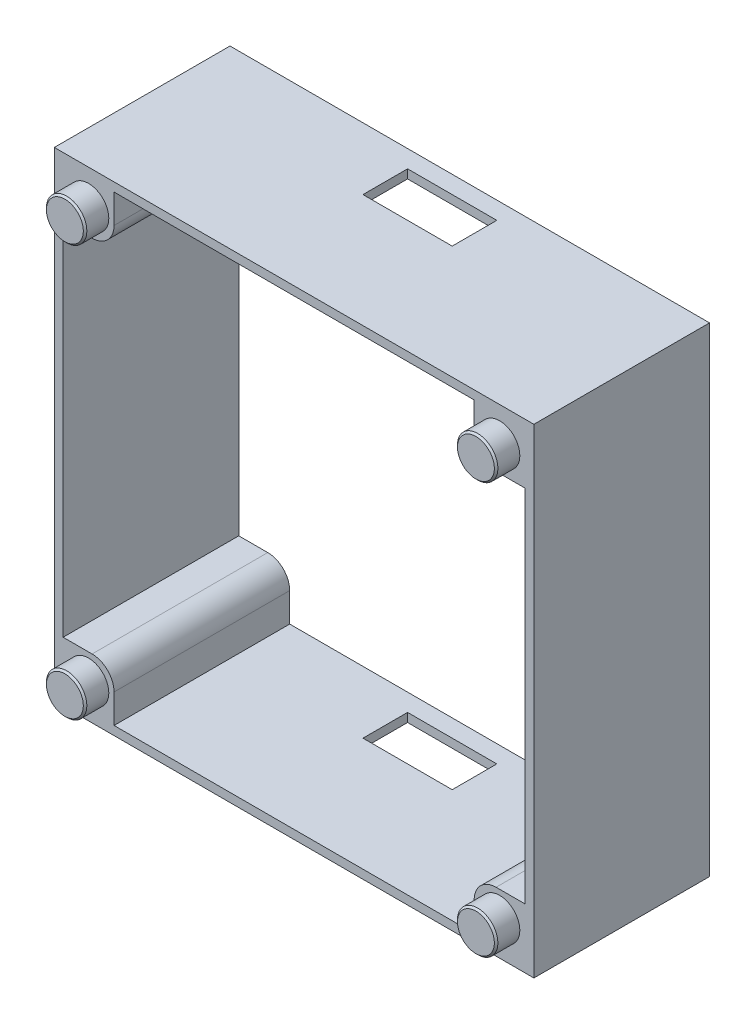
from build123d import *

# Parameters (mm, degrees)
SKICA1_W                 = 5.8
SKICA1_H                 = 5.8
SKICA1_W_2               = 1
SKICA1_H_2               = 41
SKICA1_W_3               = 41
SKICA1_H_3               = 1
P_IDAT_VYSUNUT_M2_DEPTH  = 20
ZAOBLIT1_R               = 2.5
SKICA2_R                 = 2.4
ODEBRAT_VYSUNUT_M1_DEPTH = 1.7
SKICA3_R                 = 2.3
P_IDAT_VYSUNUT_M3_DEPTH  = 2.7
ZKOSEN_1_SIZE            = 0.2
SKICA4_W                 = 10.16
SKICA4_H                 = 5.08
ODEBRAT_VYSUNUT_M2_DEPTH = 68.7


with BuildPart() as part:
    # Skica1 → Přidat vysunutím2 (new body)
    with BuildSketch(Plane.XY):
        Polygon((-27.3, 27.3), (-27.3, 20.5), (-26.3, 20.5), (-26.3, 26.3), (-20.5, 26.3), (-20.5, 27.3), align=None)
        with Locations((-23.4, 23.4)):
            Rectangle(SKICA1_W, SKICA1_H)
        Polygon((26.3, 20.5), (27.3, 20.5), (27.3, 27.3), (20.5, 27.3), (20.5, 26.3), (26.3, 26.3), align=None)
        with Locations((23.4, 23.4)):
            Rectangle(SKICA1_W, SKICA1_H)
        Polygon((20.5, -26.3), (20.5, -27.3), (27.3, -27.3), (27.3, -20.5), (26.3, -20.5), (26.3, -26.3), align=None)
        with Locations((23.4, -23.4)):
            Rectangle(SKICA1_W, SKICA1_H)
        with Locations((-23.4, -23.4)):
            Rectangle(SKICA1_W, SKICA1_H)
        Polygon((-27.3, -27.3), (-20.5, -27.3), (-20.5, -26.3), (-26.3, -26.3), (-26.3, -20.5), (-27.3, -20.5), align=None)
        with Locations((-26.8, 0)):
            Rectangle(SKICA1_W_2, SKICA1_H_2)
        with Locations((0, -26.8)):
            Rectangle(SKICA1_W_3, SKICA1_H_3)
        with Locations((26.8, 0)):
            Rectangle(SKICA1_W_2, SKICA1_H_2)
        with Locations((0, 26.8)):
            Rectangle(SKICA1_W_3, SKICA1_H_3)
    extrude(amount=P_IDAT_VYSUNUT_M2_DEPTH)

    # Zaoblit1
    zaoblit1_edges = [part.edges().sort_by_distance(p)[0] for p in [
        (20.5, -20.5, 10),
        (20.5, 20.5, 10),
        (-20.5, 20.5, 10),
        (-20.5, -20.5, 10),
    ]]
    fillet(zaoblit1_edges, radius=ZAOBLIT1_R)

    # Skica2 → Odebrat vysunutím1 (cut)
    with BuildSketch(Plane(origin=(0, 0, 0), x_dir=(-1, 0, 0), z_dir=(0, 0, -1))):
        with Locations((-23.4, 23.4)):
            Circle(SKICA2_R)
        with Locations((23.4, 23.4)):
            Circle(SKICA2_R)
        with Locations((23.4, -23.4)):
            Circle(SKICA2_R)
        with Locations((-23.4, -23.4)):
            Circle(SKICA2_R)
    extrude(amount=-ODEBRAT_VYSUNUT_M1_DEPTH, mode=Mode.SUBTRACT)

    # Skica3 → Přidat vysunutím3 (add)
    with BuildSketch(Plane.XY.offset(20)):
        with Locations((-23.4, 23.4)):
            Circle(SKICA3_R)
        with Locations((23.4, 23.4)):
            Circle(SKICA3_R)
        with Locations((23.4, -23.4)):
            Circle(SKICA3_R)
        with Locations((-23.4, -23.4)):
            Circle(SKICA3_R)
    extrude(amount=P_IDAT_VYSUNUT_M3_DEPTH)

    # Zkosení1
    zkosen_1_edges = [part.edges().sort_by_distance(p)[0] for p in [
        (-25.7, 23.4, 22.7),
        (21.1, 23.4, 22.7),
        (21.1, -23.4, 22.7),
        (-25.7, -23.4, 22.7),
    ]]
    chamfer(zkosen_1_edges, length=ZKOSEN_1_SIZE)

    # Skica4 → Odebrat vysunutím2 (cut)
    with BuildSketch(Plane(origin=(0, -27.3, 0), x_dir=(-1, 0, 0), z_dir=(0, -1, 0))):
        with Locations((0, -4.54)):
            Rectangle(SKICA4_W, SKICA4_H)
    extrude(amount=-ODEBRAT_VYSUNUT_M2_DEPTH, mode=Mode.SUBTRACT)


solid = part.part
